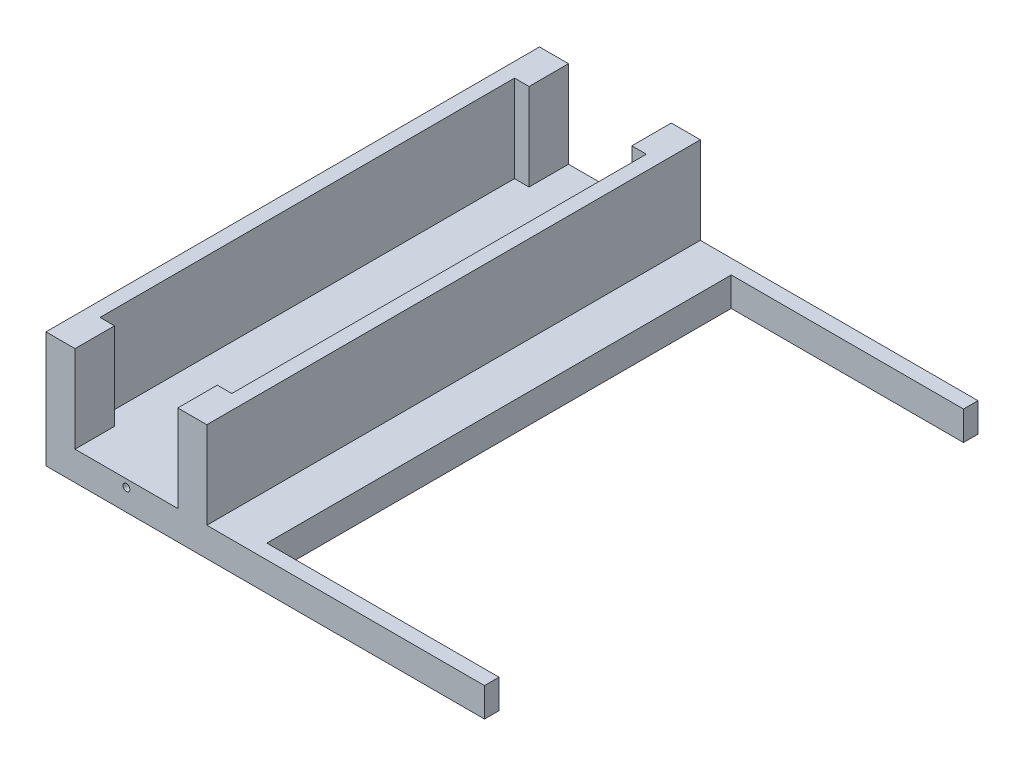
from build123d import *

# Parameters (mm, degrees)
SKETCH1_W               = 257.843094768
SKETCH1_H               = 107.95
BOSS_EXTRUDE1_DEPTH     = 6.35
BOSS_EXTRUDE2_DEPTH     = 19.05
SKETCH3_R               = 0.762
CUT_EXTRUDE1_DEPTH      = 6.35
SKETCH4_W               = 101.6
SKETCH4_H               = 101.6
CUT_EXTRUDE2_DEPTH      = 6.35
CUT_EXTRUDE3_DEPTH      = 20.574
CUT_EXTRUDE3_DEPTH_BACK = 86.614


with BuildPart() as part:
    # Sketch1 → Boss-Extrude1 (new body)
    with BuildSketch(Plane(origin=(0, 0, 0), x_dir=(1, 0, 0), z_dir=(0, 1, 0))):
        Rectangle(SKETCH1_W, SKETCH1_H)
    extrude(amount=-BOSS_EXTRUDE1_DEPTH)

    # Sketch1_3 → Boss-Extrude2 (add)
    with BuildSketch(Plane(origin=(0, 0, 0), x_dir=(1, 0, 0), z_dir=(0, 1, 0))):
        Polygon((-128.921547384, -53.975), (-122.571547384, -53.975), (-122.571547384, -45.339), (-125.746547384, -45.339), (-125.746547384, 45.339), (-122.571547384, 45.339), (-122.571547384, 53.975), (-128.921547384, 53.975), align=None)
        Polygon((-100.092547384, -45.339), (-100.092547384, -53.975), (-93.742547384, -53.975), (-93.742547384, 53.975), (-100.092547384, 53.975), (-100.092547384, 45.339), (-96.917547384, 45.339), (-96.917547384, -45.339), align=None)
    extrude(amount=BOSS_EXTRUDE2_DEPTH)

    # Sketch3 → Cut-Extrude1 (cut)
    with BuildSketch(Plane.XY.offset(53.975)):
        with Locations((-111.332047384, -1.651)):
            Circle(SKETCH3_R)
    cut_extrude1 = extrude(amount=-CUT_EXTRUDE1_DEPTH, mode=Mode.SUBTRACT)

    # Mirror1: Cut-Extrude1 across plane
    add(cut_extrude1.mirror(Plane.XY), mode=Mode.SUBTRACT)

    # Sketch4 → Cut-Extrude2 (cut)
    with BuildSketch(Plane(origin=(0, 0, 0), x_dir=(1, 0, 0), z_dir=(0, 1, 0))):
        with Locations((-33.003452616, 0)):
            Rectangle(SKETCH4_W, SKETCH4_H)
    extrude(amount=-CUT_EXTRUDE2_DEPTH, mode=Mode.SUBTRACT)

    # Sketch5 → Cut-Extrude3 (cut, two sides: drawn at the far end of the back side and taken through both)
    with BuildSketch(Plane(origin=(0, 0, 0), x_dir=(1, 0, 0), z_dir=(0, 1, 0)).offset(-CUT_EXTRUDE3_DEPTH_BACK)):
        Polygon((-33.003452616, 81.208415926), (-33.003452616, 50.8), (-33.003452616, -61.928851746), (144.325230391, -61.928851746), (144.325230391, 81.208415926), align=None)
    extrude(amount=CUT_EXTRUDE3_DEPTH + CUT_EXTRUDE3_DEPTH_BACK, mode=Mode.SUBTRACT)


solid = part.part
